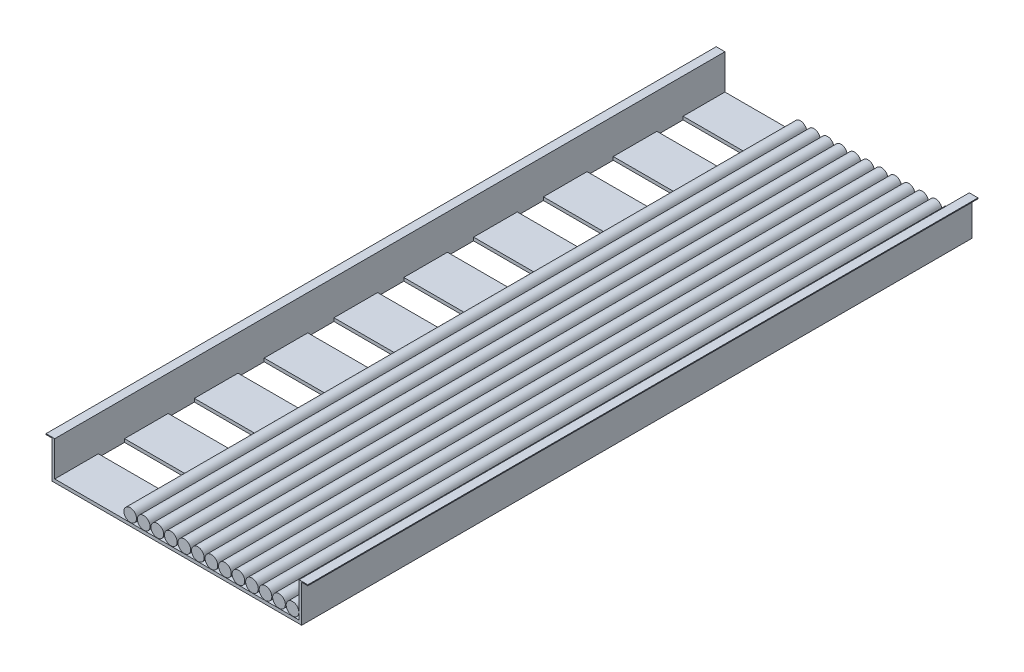
from build123d import *

# Parameters (mm, degrees)
CROQUIS1_W              = 600
CROQUIS1_H              = 120
SALIENTE_EXTRUIR1_DEPTH = 4840
CROQUIS2_W              = 560
CROQUIS2_H              = 80
CORTAR_EXTRUIR1_DEPTH   = 4840
CORTAR_EXTRUIR2_DEPTH   = 4840
CROQUIS4_W              = 560
CROQUIS4_H              = 60
CORTAR_EXTRUIR3_DEPTH   = 4000
MATRIZL1_COUNT          = 30
MATRIZL1_PITCH          = 160
CROQUIS5_R              = 14.5
SALIENTE_EXTRUIR2_DEPTH = 4840
MATRIZL2_COUNT          = 13
MATRIZL2_PITCH          = 31
CROQUIS6_W              = 600
CROQUIS6_H              = 89.724233467
CORTAR_EXTRUIR4_DEPTH   = 3304


with BuildPart() as part:
    # Croquis1 → Saliente-Extruir1 (new body)
    with BuildSketch(Plane.XY):
        Rectangle(CROQUIS1_W, CROQUIS1_H)
    extrude(amount=SALIENTE_EXTRUIR1_DEPTH)

    # Croquis2 → Cortar-Extruir1 (cut)
    with BuildSketch(Plane.XY.offset(4840)):
        with Locations((0, 20)):
            Rectangle(CROQUIS2_W, CROQUIS2_H)
    extrude(amount=-CORTAR_EXTRUIR1_DEPTH, mode=Mode.SUBTRACT)

    # Croquis3 → Cortar-Extruir2 (cut)
    with BuildSketch(Plane.XY.offset(4840)):
        Polygon((-286, 58), (-300, 58), (-300, -60), (300, -60), (300, 58), (286, 58), (286, -27.423685892), (-286, -27.423685892), align=None)
    extrude(amount=-CORTAR_EXTRUIR2_DEPTH, mode=Mode.SUBTRACT)

    # Croquis4 → Cortar-Extruir3 (cut)
    with BuildSketch(Plane(origin=(0, -20, 0), x_dir=(1, 0, 0), z_dir=(0, 1, 0))):
        with Locations((0, -4710)):
            Rectangle(CROQUIS4_W, CROQUIS4_H)
    cortar_extruir3 = extrude(amount=-CORTAR_EXTRUIR3_DEPTH, mode=Mode.SUBTRACT)

    # MatrizL1: Cortar-Extruir3 ×30
    with Locations(*[(0, 0, -i * MATRIZL1_PITCH) for i in range(1, MATRIZL1_COUNT)]):
        add(cortar_extruir3, mode=Mode.SUBTRACT)


with BuildPart() as body_2:
    # Croquis5 → Saliente-Extruir2 (new body)
    with BuildSketch(Plane(origin=(0, 0, 0), x_dir=(-1, 0, 0), z_dir=(0, 0, -1))):
        with Locations((-265, -5)):
            Circle(CROQUIS5_R)
    saliente_extruir2 = extrude(amount=-SALIENTE_EXTRUIR2_DEPTH)


with BuildPart() as matrizl2_1:
    # MatrizL2: pattern copy
    add(saliente_extruir2.moved(Location(Vector(-1, 0, 0) * (1 * MATRIZL2_PITCH))))


with BuildPart() as matrizl2_2:
    # MatrizL2: pattern copy
    add(saliente_extruir2.moved(Location(Vector(-1, 0, 0) * (2 * MATRIZL2_PITCH))))


with BuildPart() as matrizl2_3:
    # MatrizL2: pattern copy
    add(saliente_extruir2.moved(Location(Vector(-1, 0, 0) * (3 * MATRIZL2_PITCH))))


with BuildPart() as matrizl2_4:
    # MatrizL2: pattern copy
    add(saliente_extruir2.moved(Location(Vector(-1, 0, 0) * (4 * MATRIZL2_PITCH))))


with BuildPart() as matrizl2_5:
    # MatrizL2: pattern copy
    add(saliente_extruir2.moved(Location(Vector(-1, 0, 0) * (5 * MATRIZL2_PITCH))))


with BuildPart() as matrizl2_6:
    # MatrizL2: pattern copy
    add(saliente_extruir2.moved(Location(Vector(-1, 0, 0) * (6 * MATRIZL2_PITCH))))


with BuildPart() as matrizl2_7:
    # MatrizL2: pattern copy
    add(saliente_extruir2.moved(Location(Vector(-1, 0, 0) * (7 * MATRIZL2_PITCH))))


with BuildPart() as matrizl2_8:
    # MatrizL2: pattern copy
    add(saliente_extruir2.moved(Location(Vector(-1, 0, 0) * (8 * MATRIZL2_PITCH))))


with BuildPart() as matrizl2_9:
    # MatrizL2: pattern copy
    add(saliente_extruir2.moved(Location(Vector(-1, 0, 0) * (9 * MATRIZL2_PITCH))))


with BuildPart() as matrizl2_10:
    # MatrizL2: pattern copy
    add(saliente_extruir2.moved(Location(Vector(-1, 0, 0) * (10 * MATRIZL2_PITCH))))


with BuildPart() as matrizl2_11:
    # MatrizL2: pattern copy
    add(saliente_extruir2.moved(Location(Vector(-1, 0, 0) * (11 * MATRIZL2_PITCH))))


with BuildPart() as matrizl2_12:
    # MatrizL2: pattern copy
    add(saliente_extruir2.moved(Location(Vector(-1, 0, 0) * (12 * MATRIZL2_PITCH))))


with BuildPart() as cortar_extruir4_tool:
    # Croquis6 → Cortar-Extruir4 (new body)
    with BuildSketch(Plane(origin=(0, 0, 0), x_dir=(-1, 0, 0), z_dir=(0, 0, -1))):
        with Locations((0, 15.137883267)):
            Rectangle(CROQUIS6_W, CROQUIS6_H)
    extrude(amount=-CORTAR_EXTRUIR4_DEPTH)


with BuildPart() as part_1:
    add(part.part)

    # Cortar-Extruir4: cut by cortar_extruir4_tool
    add(cortar_extruir4_tool.part, mode=Mode.SUBTRACT)


with BuildPart() as body_2_1:
    add(body_2.part)

    # Cortar-Extruir4: cut by cortar_extruir4_tool
    add(cortar_extruir4_tool.part, mode=Mode.SUBTRACT)


with BuildPart() as matrizl2_1_1:
    add(matrizl2_1.part)

    # Cortar-Extruir4: cut by cortar_extruir4_tool
    add(cortar_extruir4_tool.part, mode=Mode.SUBTRACT)


with BuildPart() as matrizl2_2_1:
    add(matrizl2_2.part)

    # Cortar-Extruir4: cut by cortar_extruir4_tool
    add(cortar_extruir4_tool.part, mode=Mode.SUBTRACT)


with BuildPart() as matrizl2_3_1:
    add(matrizl2_3.part)

    # Cortar-Extruir4: cut by cortar_extruir4_tool
    add(cortar_extruir4_tool.part, mode=Mode.SUBTRACT)


with BuildPart() as matrizl2_4_1:
    add(matrizl2_4.part)

    # Cortar-Extruir4: cut by cortar_extruir4_tool
    add(cortar_extruir4_tool.part, mode=Mode.SUBTRACT)


with BuildPart() as matrizl2_5_1:
    add(matrizl2_5.part)

    # Cortar-Extruir4: cut by cortar_extruir4_tool
    add(cortar_extruir4_tool.part, mode=Mode.SUBTRACT)


with BuildPart() as matrizl2_6_1:
    add(matrizl2_6.part)

    # Cortar-Extruir4: cut by cortar_extruir4_tool
    add(cortar_extruir4_tool.part, mode=Mode.SUBTRACT)


with BuildPart() as matrizl2_7_1:
    add(matrizl2_7.part)

    # Cortar-Extruir4: cut by cortar_extruir4_tool
    add(cortar_extruir4_tool.part, mode=Mode.SUBTRACT)


with BuildPart() as matrizl2_8_1:
    add(matrizl2_8.part)

    # Cortar-Extruir4: cut by cortar_extruir4_tool
    add(cortar_extruir4_tool.part, mode=Mode.SUBTRACT)


with BuildPart() as matrizl2_9_1:
    add(matrizl2_9.part)

    # Cortar-Extruir4: cut by cortar_extruir4_tool
    add(cortar_extruir4_tool.part, mode=Mode.SUBTRACT)


with BuildPart() as matrizl2_10_1:
    add(matrizl2_10.part)

    # Cortar-Extruir4: cut by cortar_extruir4_tool
    add(cortar_extruir4_tool.part, mode=Mode.SUBTRACT)


with BuildPart() as matrizl2_11_1:
    add(matrizl2_11.part)

    # Cortar-Extruir4: cut by cortar_extruir4_tool
    add(cortar_extruir4_tool.part, mode=Mode.SUBTRACT)


with BuildPart() as matrizl2_12_1:
    add(matrizl2_12.part)

    # Cortar-Extruir4: cut by cortar_extruir4_tool
    add(cortar_extruir4_tool.part, mode=Mode.SUBTRACT)


solid = Compound([part_1.part, body_2_1.part, matrizl2_1_1.part, matrizl2_2_1.part, matrizl2_3_1.part, matrizl2_4_1.part, matrizl2_5_1.part, matrizl2_6_1.part, matrizl2_7_1.part, matrizl2_8_1.part, matrizl2_9_1.part, matrizl2_10_1.part, matrizl2_11_1.part, matrizl2_12_1.part])
